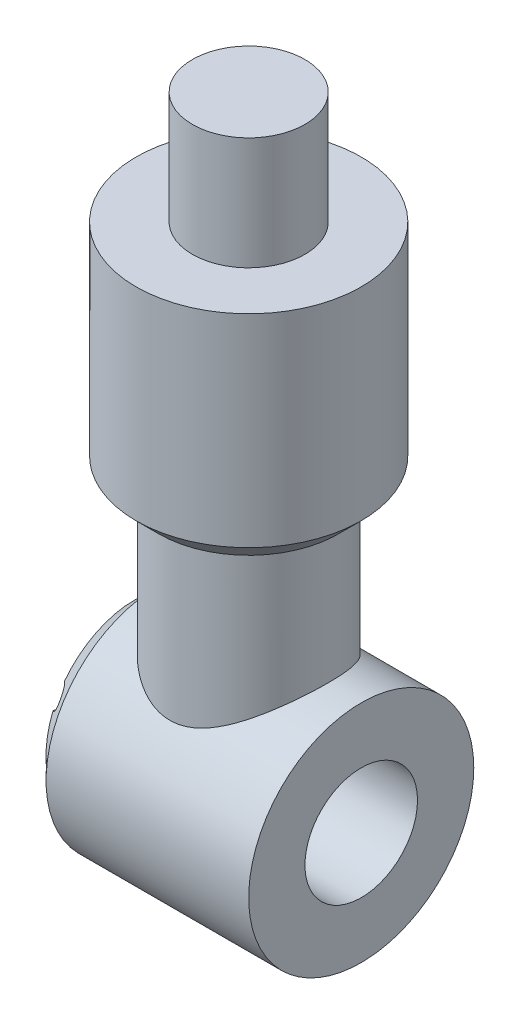
from build123d import *

# Parameters (mm, degrees)
SKETCH1_R           = 88.9
BOSS_EXTRUDE1_DEPTH = 101.6
SKETCH4_R           = 127
BOSS_EXTRUDE2_DEPTH = 127
SKETCH6_R           = 127
BOSS_EXTRUDE4_DEPTH = 254
SKETCH5_R           = 63.5
CUT_EXTRUDE1_DEPTH  = 127
SKETCH7_R           = 63.5
BOSS_EXTRUDE5_DEPTH = 127
CHAMFER1_SIZE       = 25.4
SKETCH8_R           = 12.7
CUT_EXTRUDE2_DEPTH  = 25.4
CHAMFER2_SIZE       = 25.4


with BuildPart() as part:
    # Sketch1 → Boss-Extrude1 (new body, symmetric)
    with BuildSketch(Plane(origin=(0, 0, 0), x_dir=(1, 0, 0), z_dir=(0, 1, 0))):
        Circle(SKETCH1_R)
    extrude(amount=BOSS_EXTRUDE1_DEPTH, both=True)

    # Sketch4 → Boss-Extrude2 (add, symmetric)
    with BuildSketch(Plane(origin=(0, 0, 0), x_dir=(0, 0, -1), z_dir=(1, 0, 0))):
        with Locations((0, -177.8)):
            Circle(SKETCH4_R)
    extrude(amount=BOSS_EXTRUDE2_DEPTH, both=True)

    # Sketch6 → Boss-Extrude4 (add)
    with BuildSketch(Plane(origin=(0, 101.6, 0), x_dir=(1, 0, 0), z_dir=(0, 1, 0))):
        Circle(SKETCH6_R)
    extrude(amount=BOSS_EXTRUDE4_DEPTH)

    # Sketch5 → Cut-Extrude1 (cut)
    with BuildSketch(Plane(origin=(127, 0, 0), x_dir=(0, 0, -1), z_dir=(1, 0, 0))):
        with Locations((0, -177.8)):
            Circle(SKETCH5_R)
    extrude(amount=-CUT_EXTRUDE1_DEPTH, mode=Mode.SUBTRACT)

    # Sketch7 → Boss-Extrude5 (add)
    with BuildSketch(Plane(origin=(0, 355.6, 0), x_dir=(1, 0, 0), z_dir=(0, 1, 0))):
        Circle(SKETCH7_R)
    extrude(amount=BOSS_EXTRUDE5_DEPTH)

    # Chamfer1
    chamfer1_edges = [part.edges().sort_by_distance(p)[0] for p in [
        (-127, -177.8, 127),
    ]]
    chamfer(chamfer1_edges, length=CHAMFER1_SIZE)

    # Sketch8 → Cut-Extrude2 (cut)
    with BuildSketch(Plane.ZY.offset(127)):
        with Locations((0, -76.2)):
            Circle(SKETCH8_R)
        with Locations((87.988181025, -127)):
            Circle(SKETCH8_R)
        with Locations((87.988181025, -228.6)):
            Circle(SKETCH8_R)
        with Locations((0, -279.4)):
            Circle(SKETCH8_R)
        with Locations((-87.988181024, -228.6)):
            Circle(SKETCH8_R)
        with Locations((-87.988181024, -127)):
            Circle(SKETCH8_R)
    extrude(amount=-CUT_EXTRUDE2_DEPTH, mode=Mode.SUBTRACT)

    # Chamfer2
    chamfer2_edges = [part.edges().sort_by_distance(p)[0] for p in [
        (-127, 101.6, 0),
    ]]
    chamfer(chamfer2_edges, length=CHAMFER2_SIZE)


solid = part.part
